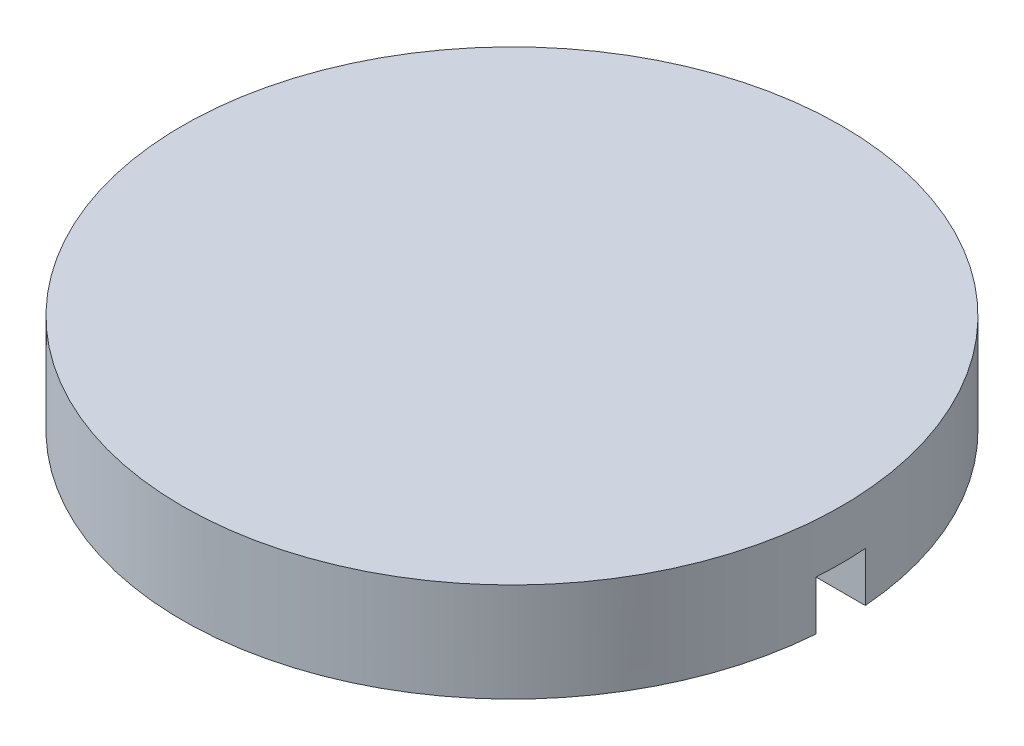
from build123d import *

# Parameters (mm, degrees)
ESBO_O1_W                  = 200
ESBO_O1_H                  = 60
ESBO_O2_W                  = 30
ESBO_O2_H                  = 30
CORTE_EXTRUS_O1_DEPTH      = 201
CORTE_EXTRUS_O1_DEPTH_BACK = 201


with BuildPart() as part:
    # Esboço1 → Revolução1 (revolve)
    with BuildSketch(Plane.XY):
        with Locations((100, 30)):
            Rectangle(ESBO_O1_W, ESBO_O1_H)
    revolve(axis=Axis((0, 0, 0), (0, 1, 0)))

    # Esboço2 → Corte-extrusão1 (cut, two sides)
    with BuildSketch(Plane(origin=(0, 0, 0), x_dir=(0, 0, -1), z_dir=(1, 0, 0))) as corte_extrus_o1_sk:
        with Locations((0, 15)):
            Rectangle(ESBO_O2_W, ESBO_O2_H)
    extrude(amount=CORTE_EXTRUS_O1_DEPTH, mode=Mode.SUBTRACT)
    extrude(corte_extrus_o1_sk.sketch, amount=-CORTE_EXTRUS_O1_DEPTH_BACK, mode=Mode.SUBTRACT)


solid = part.part
